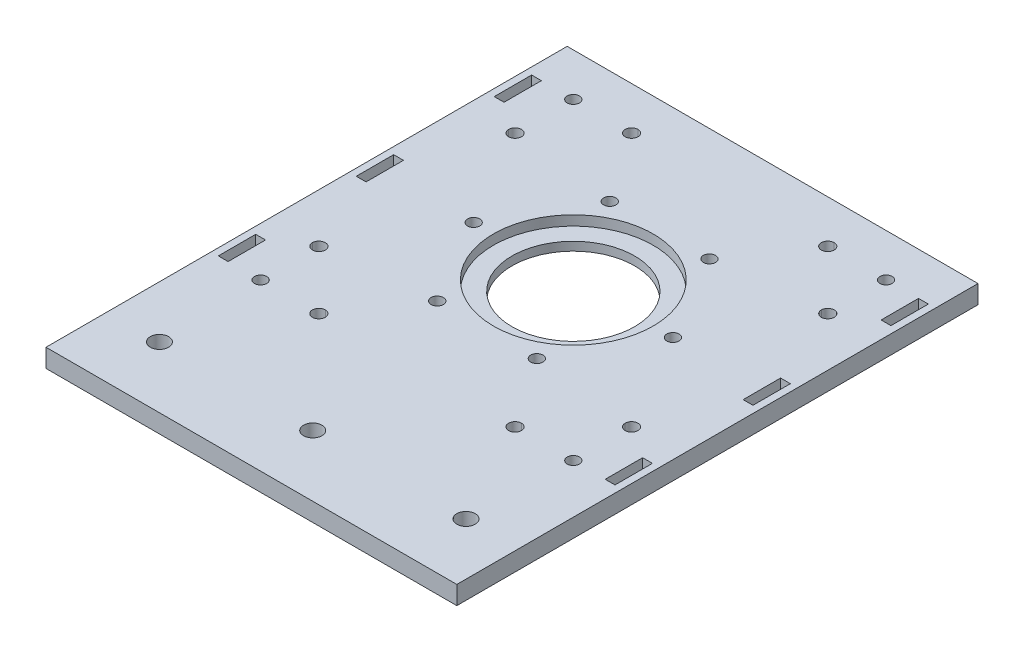
from build123d import *

# Parameters (mm, degrees)
SKETCH15_W          = 130
SKETCH15_H          = 130
SKETCH15_R          = 20
SKETCH15_R_2        = 2
BOSS_EXTRUDE1_DEPTH = 6
SKETCH16_R          = 26.05
CUT_EXTRUDE6_DEPTH  = 3.2
SKETCH17_R          = 2
CUT_EXTRUDE7_DEPTH  = 7
SKETCH18_W          = 130
SKETCH18_H          = 40
SKETCH18_R          = 3
BOSS_EXTRUDE2_DEPTH = 6
SKETCH21_W          = 2
SKETCH21_H          = 170
BOSS_EXTRUDE3_DEPTH = 6
SKETCH20_W          = 3.2
SKETCH20_H          = 12.2
CUT_EXTRUDE8_DEPTH  = 10


with BuildPart() as part:
    # Sketch15 → Boss-Extrude1 (new body)
    with BuildSketch(Plane(origin=(0, 0, 0), x_dir=(1, 0, 0), z_dir=(0, 1, 0))):
        Rectangle(SKETCH15_W, SKETCH15_H)
        Circle(SKETCH15_R, mode=Mode.SUBTRACT)
        with Locations((32.5, 0)):
            Circle(SKETCH15_R_2, mode=Mode.SUBTRACT)
        with Locations((16.25, -28.145825623)):
            Circle(SKETCH15_R_2, mode=Mode.SUBTRACT)
        with Locations((-16.25, -28.145825623)):
            Circle(SKETCH15_R_2, mode=Mode.SUBTRACT)
        with Locations((-32.5, 0)):
            Circle(SKETCH15_R_2, mode=Mode.SUBTRACT)
        with Locations((-16.25, 28.145825623)):
            Circle(SKETCH15_R_2, mode=Mode.SUBTRACT)
        with Locations((16.25, 28.145825623)):
            Circle(SKETCH15_R_2, mode=Mode.SUBTRACT)
    extrude(amount=BOSS_EXTRUDE1_DEPTH)

    # Sketch16 → Cut-Extrude6 (cut)
    with BuildSketch(Plane(origin=(0, 6, 0), x_dir=(1, 0, 0), z_dir=(0, 1, 0))):
        Circle(SKETCH16_R)
    extrude(amount=-CUT_EXTRUDE6_DEPTH, mode=Mode.SUBTRACT)

    # Sketch17 → Cut-Extrude7 (cut, through all)
    with BuildSketch(Plane.XZ):
        with Locations((-51, 51)):
            Circle(SKETCH17_R)
        with BuildLine():
            ThreePointArc((-31.999, 53.1), (-29.899, 51), (-31.999, 48.9))
            Line((-31.999, 48.9), (-32, 48.9))
            ThreePointArc((-32, 48.9), (-34.1, 51), (-32, 53.1))
            Line((-32, 53.1), (-31.999, 53.1))
        make_face()
        with BuildLine():
            Line((-53.1, 32), (-53.1, 31.999))
            ThreePointArc((-53.1, 31.999), (-51, 29.899), (-48.9, 31.999))
            Line((-48.9, 31.999), (-48.9, 32))
            ThreePointArc((-48.9, 32), (-51, 34.1), (-53.1, 32))
        make_face()
        with Locations((51, 51)):
            Circle(SKETCH17_R)
        with BuildLine():
            ThreePointArc((53.1, 31.999), (51, 29.899), (48.9, 31.999))
            Line((48.9, 31.999), (48.9, 32))
            ThreePointArc((48.9, 32), (51, 34.1), (53.1, 32))
            Line((53.1, 32), (53.1, 31.999))
        make_face()
        with Locations((51, -51)):
            Circle(SKETCH17_R)
        with BuildLine():
            Line((53.1, -32), (53.1, -31.999))
            ThreePointArc((53.1, -31.999), (51, -29.899), (48.9, -31.999))
            Line((48.9, -31.999), (48.9, -32))
            ThreePointArc((48.9, -32), (51, -34.1), (53.1, -32))
        make_face()
        with BuildLine():
            ThreePointArc((31.999, -53.1), (29.899, -51), (31.999, -48.9))
            Line((31.999, -48.9), (32, -48.9))
            ThreePointArc((32, -48.9), (34.1, -51), (32, -53.1))
            Line((32, -53.1), (31.999, -53.1))
        make_face()
        with BuildLine():
            ThreePointArc((-32, -53.1), (-34.1, -51), (-32, -48.9))
            Line((-32, -48.9), (-31.999, -48.9))
            ThreePointArc((-31.999, -48.9), (-29.899, -51), (-31.999, -53.1))
            Line((-31.999, -53.1), (-32, -53.1))
        make_face()
        with Locations((-51, -51)):
            Circle(SKETCH17_R)
        with BuildLine():
            Line((-53.1, -32), (-53.1, -31.999))
            ThreePointArc((-53.1, -31.999), (-51, -29.899), (-48.9, -31.999))
            Line((-48.9, -31.999), (-48.9, -32))
            ThreePointArc((-48.9, -32), (-51, -34.1), (-53.1, -32))
        make_face()
        with BuildLine():
            ThreePointArc((32, 53.1), (34.1, 51), (32, 48.9))
            Line((32, 48.9), (31.999, 48.9))
            ThreePointArc((31.999, 48.9), (29.899, 51), (31.999, 53.1))
            Line((31.999, 53.1), (32, 53.1))
        make_face()
    extrude(amount=-CUT_EXTRUDE7_DEPTH, mode=Mode.SUBTRACT)

    # Sketch18 → Boss-Extrude2 (add)
    with BuildSketch(Plane(origin=(0, 6, 0), x_dir=(1, 0, 0), z_dir=(0, 1, 0))):
        with Locations((0, -85)):
            Rectangle(SKETCH18_W, SKETCH18_H)
        with Locations((50, -85)):
            Circle(SKETCH18_R, mode=Mode.SUBTRACT)
        with Locations((0, -85)):
            Circle(SKETCH18_R, mode=Mode.SUBTRACT)
        with Locations((-50, -85)):
            Circle(SKETCH18_R, mode=Mode.SUBTRACT)
    extrude(amount=-BOSS_EXTRUDE2_DEPTH)

    # Sketch21 → Boss-Extrude3 (add)
    with BuildSketch(Plane(origin=(0, 6, 0), x_dir=(1, 0, 0), z_dir=(0, 1, 0))):
        with Locations((-66, -20)):
            Rectangle(SKETCH21_W, SKETCH21_H)
        with Locations((66, -20)):
            Rectangle(SKETCH21_W, SKETCH21_H)
    extrude(amount=-BOSS_EXTRUDE3_DEPTH)

    # Sketch20 → Cut-Extrude8 (cut)
    with BuildSketch(Plane(origin=(0, 6, 0), x_dir=(1, 0, 0), z_dir=(0, 1, 0))):
        with Locations((-63.1, 45)):
            Rectangle(SKETCH20_W, SKETCH20_H)
        with Locations((-63.1, 0)):
            Rectangle(SKETCH20_W, SKETCH20_H)
        with Locations((-63.1, -45)):
            Rectangle(SKETCH20_W, SKETCH20_H)
        with Locations((63.1, -45)):
            Rectangle(SKETCH20_W, SKETCH20_H)
        with Locations((63.1, 0)):
            Rectangle(SKETCH20_W, SKETCH20_H)
        with Locations((63.1, 45)):
            Rectangle(SKETCH20_W, SKETCH20_H)
    extrude(amount=-CUT_EXTRUDE8_DEPTH, mode=Mode.SUBTRACT)


solid = part.part
